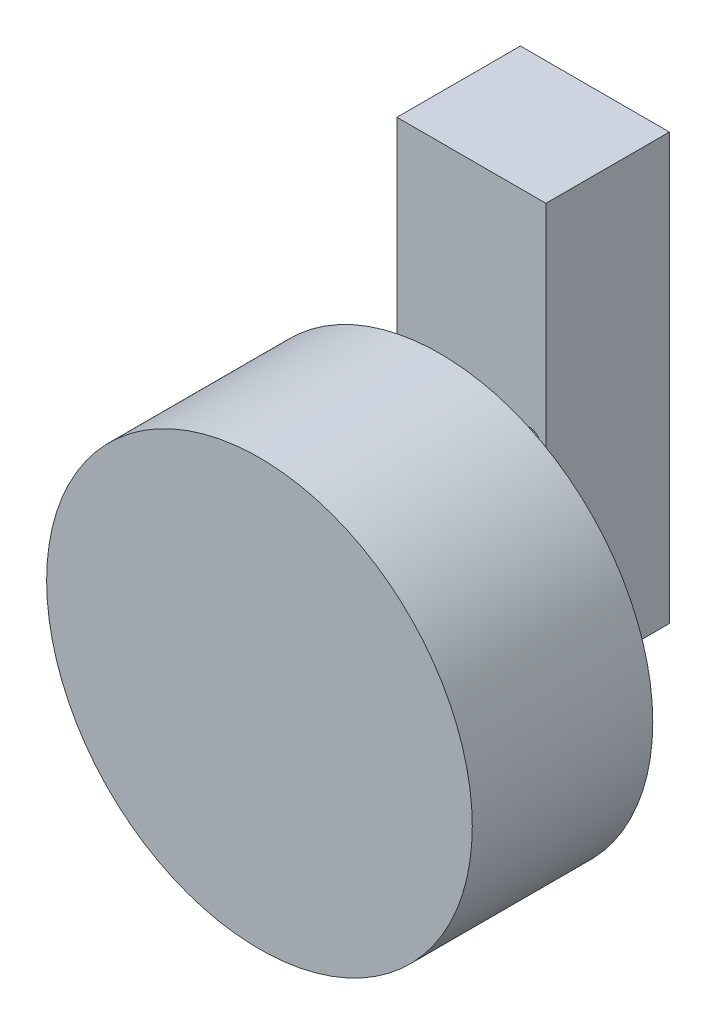
from build123d import *

# Parameters (mm, degrees)
SKETCH1_W           = 22.225
SKETCH1_H           = 63.5
SKETCH1_R           = 1.5875
BOSS_EXTRUDE1_DEPTH = 18.415
SKETCH2_R           = 6.985
BOSS_EXTRUDE2_DEPTH = 4.699
SKETCH3_R           = 31.75
BOSS_EXTRUDE3_DEPTH = 26.924


with BuildPart() as part:
    # Sketch1 → Boss-Extrude1 (new body)
    with BuildSketch(Plane.XY):
        with Locations((-21.669088448, 0.687725632)):
            Rectangle(SKETCH1_W, SKETCH1_H)
        with Locations((-30.368588448, 0.687725632)):
            Circle(SKETCH1_R, mode=Mode.SUBTRACT)
        with Locations((-12.969588448, 0.687725632)):
            Circle(SKETCH1_R, mode=Mode.SUBTRACT)
    extrude(amount=BOSS_EXTRUDE1_DEPTH)

    # Sketch2 → Boss-Extrude2 (add)
    with BuildSketch(Plane.XY.offset(18.415)):
        with Locations((-21.669088448, -21.918274368)):
            Circle(SKETCH2_R)
    extrude(amount=BOSS_EXTRUDE2_DEPTH)

    # Sketch3 → Boss-Extrude3 (add)
    with BuildSketch(Plane.XY.offset(23.114)):
        with Locations((-21.669088448, -21.918274368)):
            Circle(SKETCH3_R)
    extrude(amount=BOSS_EXTRUDE3_DEPTH)


solid = part.part
